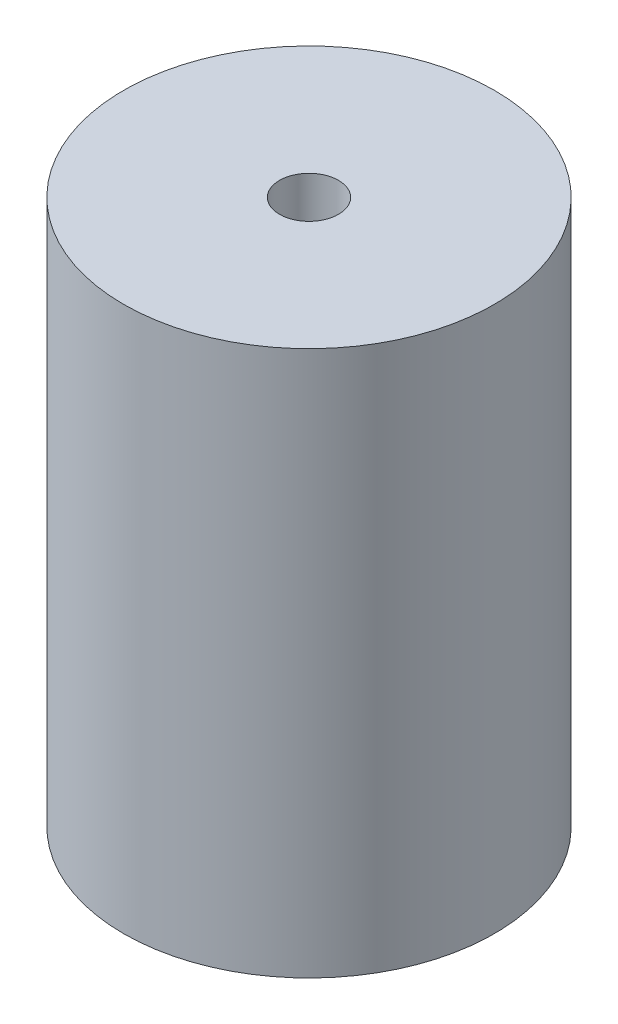
from build123d import *

# Parameters (mm, degrees)
SKETCH1_R                      = 12.7
BOSS_EXTRUDE1_DEPTH            = 18.669
TAP_DRILL_FOR_10_32_TAP1_D     = 4.0386
TAP_DRILL_FOR_10_32_TAP1_DEPTH = 37.338


with BuildPart() as part:
    # Sketch1 → Boss-Extrude1 (new body, symmetric)
    with BuildSketch(Plane(origin=(0, 0, 0), x_dir=(1, 0, 0), z_dir=(0, 1, 0))):
        Circle(SKETCH1_R)
    extrude(amount=BOSS_EXTRUDE1_DEPTH, both=True)

    # Tap Drill for #10-32 Tap1
    with Locations(Plane(origin=(0, 18.669, 0), x_dir=(1, 0, 0), z_dir=(0, 1, 0))):
        with Locations((0, 0)):
            Hole(TAP_DRILL_FOR_10_32_TAP1_D / 2, depth=TAP_DRILL_FOR_10_32_TAP1_DEPTH)


solid = part.part
